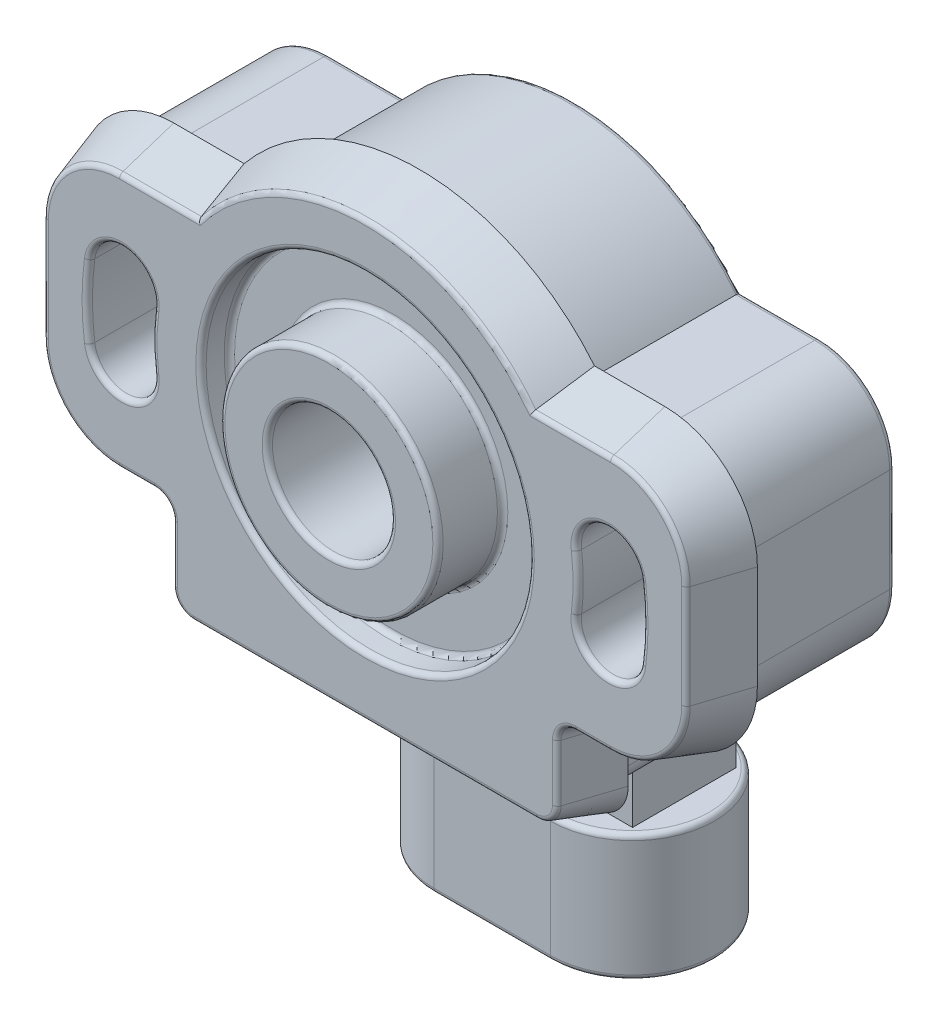
from build123d import *

# Parameters (mm, degrees)
BODY_DEPTH               = 16.2
LID_DRAFT_DEPTH          = 4.2
LID_DRAFT_DRAFT          = 18
SKETCH4_R                = 12.7
CUT_EXTRUDE1_DEPTH       = 2.2
SKETCH5_R                = 8.45
BOSS_EXTRUDE2_DEPTH      = 5
SKETCH6_R                = 4.7625
F_3_8_HOLE_DEPTH         = 16.6
KEY_START                = 12.8
KEY_DEPTH                = 12.8
CUT_EXTRUDE3_DEPTH       = 36.939898129
SKETCH13_W               = 17
SKETCH13_H               = 8
BOSS_EXTRUDE5_DEPTH      = 20.4
BOSS_EXTRUDE6_DEPTH      = 9.8
CUT_EXTRUDE4_DEPTH       = 8.2
BOSS_EXTRUDE7_DEPTH      = 0.8
BOSS_EXTRUDE8_DEPTH      = 0.8
BOSS_EXTRUDE9_DEPTH      = 0.4
BOSS_EXTRUDE9_DEPTH_BACK = 0.4
FILLET2_R                = 0.4


with BuildPart() as part:
    # Sketch3 → Body (new body)
    with BuildSketch(Plane.XY):
        with BuildLine():
            Line((19, 9.8), (12.899612397, 9.8))
            ThreePointArc((12.899612397, 9.8), (0, 16.2), (-12.899612397, 9.8))
            Line((-12.899612397, 9.8), (-19, 9.8))
            ThreePointArc((-19, 9.8), (-23.101219331, 8.101219331), (-24.8, 4))
            Line((-24.8, 4), (-24.8, -4))
            ThreePointArc((-24.8, -4), (-23.101219331, -8.101219331), (-19, -9.8))
            Line((-19, -9.8), (-16.3, -9.8))
            ThreePointArc((-16.3, -9.8), (-15.239339828, -10.239339828), (-14.8, -11.3))
            Line((-14.8, -11.3), (-14.8, -15.7))
            ThreePointArc((-14.8, -15.7), (-14.360660172, -16.760660172), (-13.3, -17.2))
            Line((-13.3, -17.2), (13.3, -17.2))
            ThreePointArc((13.3, -17.2), (14.360660172, -16.760660172), (14.8, -15.7))
            Line((14.8, -15.7), (14.8, -11.3))
            ThreePointArc((14.8, -11.3), (15.239339828, -10.239339828), (16.3, -9.8))
            Line((16.3, -9.8), (19, -9.8))
            ThreePointArc((19, -9.8), (23.101219331, -8.101219331), (24.8, -4))
            Line((24.8, -4), (24.8, 4))
            ThreePointArc((24.8, 4), (23.101219331, 8.101219331), (19, 9.8))
        make_face()
    extrude(amount=BODY_DEPTH)


with BuildPart() as lid_draft_tool:
    # Sketch11 → Lid Draft (with draft: the straight prism first)
    with BuildSketch(Plane.XY.offset(16.2)):
        with BuildLine():
            ThreePointArc((-19, 9.8), (-23.101219331, 8.101219331), (-24.8, 4))
            Line((-24.8, 4), (-24.8, -4))
            ThreePointArc((-24.8, -4), (-23.101219331, -8.101219331), (-19, -9.8))
            Line((-19, -9.8), (-16.3, -9.8))
            ThreePointArc((-16.3, -9.8), (-15.239339828, -10.239339828), (-14.8, -11.3))
            Line((-14.8, -11.3), (-14.8, -15.7))
            ThreePointArc((-14.8, -15.7), (-14.360660172, -16.760660172), (-13.3, -17.2))
            Line((-13.3, -17.2), (13.3, -17.2))
            ThreePointArc((13.3, -17.2), (14.360660172, -16.760660172), (14.8, -15.7))
            Line((14.8, -15.7), (14.8, -11.3))
            ThreePointArc((14.8, -11.3), (15.239339828, -10.239339828), (16.3, -9.8))
            Line((16.3, -9.8), (19, -9.8))
            ThreePointArc((19, -9.8), (23.101219331, -8.101219331), (24.8, -4))
            Line((24.8, -4), (24.8, 4))
            ThreePointArc((24.8, 4), (23.101219331, 8.101219331), (19, 9.8))
            Line((19, 9.8), (12.899612397, 9.8))
            ThreePointArc((12.899612397, 9.8), (0, 16.2), (-12.899612397, 9.8))
            Line((-12.899612397, 9.8), (-19, 9.8))
        make_face()
    extrude(amount=-LID_DRAFT_DEPTH)
    # Lid Draft: the draft: its side faces are tilted about the plane it starts from
    lid_draft_sides = [lid_draft_tool.faces().sort_by_distance(p)[0] for p in [
        (-15.949806199, 9.8, 14.1),
        (-23.101219331, 8.101219331, 14.1),
        (-24.8, 0, 14.1),
        (-23.101219331, -8.101219331, 14.1),
        (-17.65, -9.8, 14.1),
        (-15.239339828, -10.239339828, 14.1),
        (-14.8, -13.5, 14.1),
        (-14.360660172, -16.760660172, 14.1),
        (0, -17.2, 14.1),
        (14.360660172, -16.760660172, 14.1),
        (14.8, -13.5, 14.1),
        (15.239339828, -10.239339828, 14.1),
        (17.65, -9.8, 14.1),
        (23.101219331, -8.101219331, 14.1),
        (24.8, 0, 14.1),
        (23.101219331, 8.101219331, 14.1),
        (15.949806199, 9.8, 14.1),
        (0, 16.2, 14.1),
    ]]
    draft(lid_draft_sides, Plane.XY.offset(16.2), LID_DRAFT_DRAFT)


with BuildPart() as part_1:
    add(part.part)

    # Lid Draft: add lid_draft_tool
    add(lid_draft_tool.part)

    # Sketch4 → Cut-Extrude1 (cut)
    with BuildSketch(Plane.XY.offset(16.2)):
        Circle(SKETCH4_R)
    extrude(amount=-CUT_EXTRUDE1_DEPTH, mode=Mode.SUBTRACT)

    # Sketch5 → Boss-Extrude2 (add)
    with BuildSketch(Plane.XY.offset(14)):
        Circle(SKETCH5_R)
    extrude(amount=BOSS_EXTRUDE2_DEPTH)

    # Sketch6 → 3_8 Hole (cut)
    with BuildSketch(Plane.XY.offset(19)):
        Circle(SKETCH6_R)
    extrude(amount=-F_3_8_HOLE_DEPTH, mode=Mode.SUBTRACT)

    # Sketch7 → Key (add)
    with BuildSketch(Plane.XY.offset(2.4).offset(KEY_START)):
        with BuildLine():
            Line((0.719230947, 2.745744543), (2.018269053, 1.995744543))
            Line((2.018269053, 1.995744543), (3.001056117, 3.69798167))
            ThreePointArc((3.001056117, 3.69798167), (2.38125, 4.124445986), (1.702018011, 4.44798167))
            Line((1.702018011, 4.44798167), (0.719230947, 2.745744543))
        make_face()
    extrude(amount=-KEY_DEPTH)

    # Sketch12 → Cut-Extrude3 (cut, through all)
    with BuildSketch(Plane.XY.offset(16.2)):
        with BuildLine():
            ThreePointArc((21.31606452, -2.806313133), (21.5, 0), (21.31606452, 2.806313133))
            ThreePointArc((21.31606452, 2.806313133), (18.511136886, 4.958609806), (16.358840213, 2.153682172))
            ThreePointArc((16.358840213, 2.153682172), (16.5, 0), (16.358840213, -2.153682172))
            ThreePointArc((16.358840213, -2.153682172), (18.511136886, -4.958609806), (21.31606452, -2.806313133))
        make_face()
        with BuildLine():
            ThreePointArc((-21.31606452, -2.806313133), (-21.5, 0), (-21.31606452, 2.806313133))
            ThreePointArc((-21.31606452, 2.806313133), (-18.511136886, 4.958609806), (-16.358840213, 2.153682172))
            ThreePointArc((-16.358840213, 2.153682172), (-16.5, 0), (-16.358840213, -2.153682172))
            ThreePointArc((-16.358840213, -2.153682172), (-18.511136886, -4.958609806), (-21.31606452, -2.806313133))
        make_face()
    extrude(amount=-CUT_EXTRUDE3_DEPTH, mode=Mode.SUBTRACT)

    # Sketch13 → Boss-Extrude5 (add)
    with BuildSketch(Plane(origin=(0, -15.7, 0), x_dir=(1, 0, 0), z_dir=(0, 1, 0))):
        Rectangle(SKETCH13_W, SKETCH13_H)
    extrude(amount=-BOSS_EXTRUDE5_DEPTH)

    # Sketch14 → Boss-Extrude6 (add)
    with BuildSketch(Plane.XZ.offset(36.1)):
        with BuildLine():
            Line((4.5, -6.35), (-4.5, -6.35))
            ThreePointArc((-4.5, -6.35), (-10.85, 0), (-4.5, 6.35))
            Line((-4.5, 6.35), (4.5, 6.35))
            ThreePointArc((4.5, 6.35), (10.85, 0), (4.5, -6.35))
        make_face()
    extrude(amount=-BOSS_EXTRUDE6_DEPTH)

    # Sketch15 → Cut-Extrude4 (cut)
    with BuildSketch(Plane.XZ.offset(36.1)):
        with BuildLine():
            Line((4.5, 4.85), (-4.5, 4.85))
            ThreePointArc((-4.5, 4.85), (-9.35, 0), (-4.5, -4.85))
            Line((-4.5, -4.85), (4.5, -4.85))
            ThreePointArc((4.5, -4.85), (9.35, 0), (4.5, 4.85))
        make_face()
    extrude(amount=-CUT_EXTRUDE4_DEPTH, mode=Mode.SUBTRACT)

    # Sketch16 → Boss-Extrude7 (add)
    with BuildSketch(Plane.ZY.offset(8.5)):
        Polygon((-4, -15.7), (-4, 2.1), (0, 8.7), (0, -15.7), align=None)
    extrude(amount=-BOSS_EXTRUDE7_DEPTH)

    # Sketch17 → Boss-Extrude8 (add)
    with BuildSketch(Plane(origin=(8.5, 0, 0), x_dir=(0, 0, -1), z_dir=(1, 0, 0))):
        Polygon((0, -15.7), (4, -15.7), (4, 2.1), (0, 8.7), align=None)
    extrude(amount=-BOSS_EXTRUDE8_DEPTH)

    # Sketch18 → Boss-Extrude9 (add, two sides: drawn at the far end of the back side and taken through both)
    with BuildSketch(Plane.ZY.offset(-BOSS_EXTRUDE9_DEPTH_BACK)):
        Polygon((0, -15.7), (0, -6), (-2.8, -10.7), (-2.8, -15.7), align=None)
    extrude(amount=BOSS_EXTRUDE9_DEPTH + BOSS_EXTRUDE9_DEPTH_BACK)

    # Fillet2
    fillet2_edges = [part_1.edges().sort_by_distance(p)[0] for p in [
        (0, -26.3, 6.35),
        (10.85, -26.3, 0),
        (0, -26.3, -6.35),
        (-21.5, 0, 0),
        (-18.511136886, 4.958609806, 0),
        (-16.5, 0, 0),
        (16.5, 0, 0),
        (18.511136886, 4.958609806, 0),
        (21.5, 0, 0),
        (10.9, -17.2, 0),
        (14.360660172, -16.760660172, 0),
        (15.949806199, 9.8, 0),
        (23.101219331, 8.101219331, 0),
        (24.8, 0, 0),
        (23.101219331, -8.101219331, 0),
        (17.65, -9.8, 0),
        (15.239339828, -10.239339828, 0),
        (-10.9, -17.2, 0),
        (-14.360660172, -16.760660172, 0),
        (-14.8, -13.5, 0),
        (-15.239339828, -10.239339828, 0),
        (-17.65, -9.8, 0),
        (-23.101219331, -8.101219331, 0),
        (-24.8, 0, 0),
        (-23.101219331, 8.101219331, 0),
        (0, -36.1, -6.35),
        (-10.85, -36.1, 0),
        (0, -36.1, 6.35),
        (10.85, -36.1, 0),
        (-9.35, -36.1, 0),
        (0, -36.1, -4.85),
        (9.35, -36.1, 0),
        (0, -36.1, 4.85),
        (-8.45, 0, 19),
        (-4.7625, 0, 19),
        (-12.7, 0, 14),
        (-8.45, 0, 14),
        (-18.511136886, 4.958609806, 16.2),
        (-21.5, 0, 16.2),
        (-18.511136886, -4.958609806, 16.2),
        (-16.5, 0, 16.2),
        (0, 16.2, 16.2),
        (15.949806199, 9.8, 16.2),
        (23.101219331, 8.101219331, 16.2),
        (24.8, 0, 16.2),
        (23.101219331, -8.101219331, 16.2),
        (17.65, -9.8, 16.2),
        (15.239339828, -10.239339828, 16.2),
        (14.8, -13.5, 16.2),
        (14.360660172, -16.760660172, 16.2),
        (0, -17.2, 16.2),
        (-14.360660172, -16.760660172, 16.2),
        (-14.8, -13.5, 16.2),
        (-15.239339828, -10.239339828, 16.2),
        (-17.65, -9.8, 16.2),
        (-23.101219331, -8.101219331, 16.2),
        (-24.8, 0, 16.2),
        (-23.101219331, 8.101219331, 16.2),
        (-15.949806199, 9.8, 16.2),
        (-12.7, 0, 16.2),
        (18.511136886, 4.958609806, 16.2),
        (16.5, 0, 16.2),
        (18.511136886, -4.958609806, 16.2),
        (21.5, 0, 16.2),
        (-10.85, -26.3, 0),
        (-18.511136886, -4.958609806, 0),
        (18.511136886, -4.958609806, 0),
        (14.8, -13.5, 0),
        (-15.949806199, 9.8, 0),
        (0, 16.2, 0),
    ]]
    fillet(fillet2_edges, radius=FILLET2_R)


solid = part_1.part
